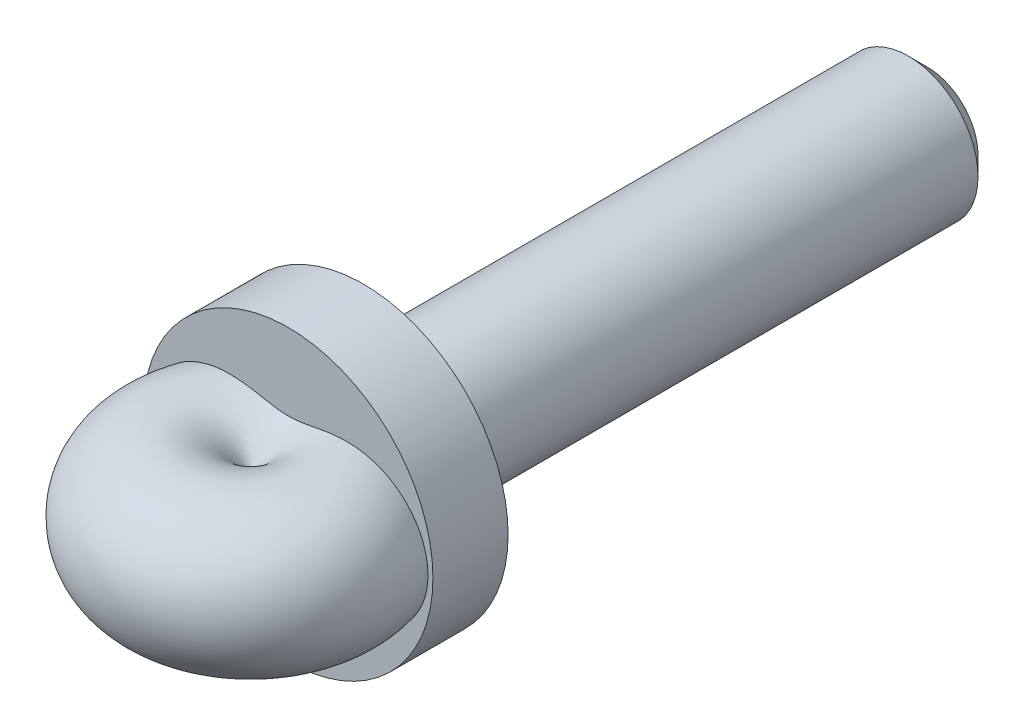
from build123d import *

# Parameters (mm, degrees)
SKETCH1_R           = 4.699
BOSS_EXTRUDE1_DEPTH = 38.1
SKETCH2_R           = 9.779
SKETCH2_R_2         = 4.699
BOSS_EXTRUDE2_DEPTH = 5.08
CHAMFER1_SIZE       = 1.27
SKETCH4_R           = 9.779
SKETCH4_R_2         = 4.699
CUT_EXTRUDE1_DEPTH  = 9.398


with BuildPart() as part:
    # Sketch1 → Boss-Extrude1 (new body)
    with BuildSketch(Plane.XY):
        with Locations(Location((0, 0, 0), (0, 0, 180))):
            Circle(SKETCH1_R)
    extrude(amount=BOSS_EXTRUDE1_DEPTH)

    # Sketch2 → Boss-Extrude2 (add)
    with BuildSketch(Plane.XY.offset(38.1)):
        Circle(SKETCH2_R)
        with Locations(Location((0, 0, 0), (0, 0, 180))):
            Circle(SKETCH2_R_2, mode=Mode.SUBTRACT)
        with Locations(Location((0, 0, 0), (0, 0, 180))):
            Circle(SKETCH2_R_2)
    extrude(amount=BOSS_EXTRUDE2_DEPTH)

    # Sketch3 → Revolve2 (revolve)
    with BuildSketch(Plane.XY.offset(45.72)):
        with BuildLine():
            Line((0, -1.930232888), (0, 1.930232888))
            ThreePointArc((0, 1.930232888), (9.779, 0), (0, -1.930232888))
        make_face()
    revolve(axis=Axis((0, -1.930232888, 45.72), (0, 1, 0)))

    # Chamfer1
    chamfer1_edges = [part.edges().sort_by_distance(p)[0] for p in [
        (4.699, 0, 0),
    ]]
    chamfer(chamfer1_edges, length=CHAMFER1_SIZE)

    # Sketch4 → Cut-Extrude1 (cut)
    with BuildSketch(Plane(origin=(0, 0, 38.1), x_dir=(-1, 0, 0), z_dir=(0, 0, -1))):
        with Locations(Location((0, 0, 0), (0, 0, 180))):
            Circle(SKETCH4_R)
        Circle(SKETCH4_R_2, mode=Mode.SUBTRACT)
    extrude(amount=CUT_EXTRUDE1_DEPTH, mode=Mode.SUBTRACT)


solid = part.part
